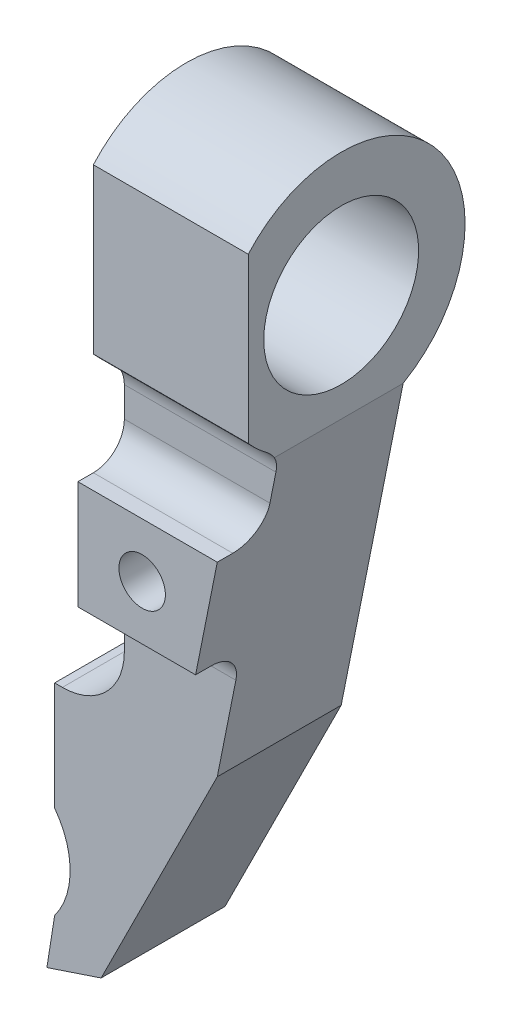
from build123d import *

# Parameters (mm, degrees)
BOSS_EXTRU_1_DEPTH           = 8
CONG_1_R                     = 4
ESQUISSE2_R                  = 5
ENL_V_MAT_EXTRU_1_DEPTH      = 9
BOSS_EXTRU_2_DEPTH           = 8
ESQUISSE4_R                  = 5
BOSS_EXTRU_3_DEPTH           = 10
ENL_V_MAT_EXTRU_2_DEPTH      = 1
ENL_V_MAT_EXTRU_2_DEPTH_BACK = 16
BOSS_EXTRU_4_DEPTH           = 3
CONG_2_R                     = 2
ESQUISSE7_R                  = 1.5
ENL_V_MAT_EXTRU_3_DEPTH      = 16


with BuildPart() as part:
    # Esquisse1 → Boss.-Extru.1 (new body)
    with BuildSketch(Plane.XY):
        Polygon((0, 0), (10, 0), (6, -20), (-1.5, -35), (-4.5, -36), (-4.5, -20), (0, -20), align=None)
    extrude(amount=BOSS_EXTRU_1_DEPTH)

    # Congé1
    cong_1_edges = [part.edges().sort_by_distance(p)[0] for p in [
        (0, -20, 4),
    ]]
    fillet(cong_1_edges, radius=CONG_1_R)

    # Esquisse2 → Enlèv. mat.-Extru.1 (cut, through all)
    with BuildSketch(Plane.XY.offset(8)):
        with Locations((-8.5, -30)):
            Circle(ESQUISSE2_R)
    extrude(amount=-ENL_V_MAT_EXTRU_1_DEPTH, mode=Mode.SUBTRACT)

    # Esquisse3 → Boss.-Extru.2 (add)
    with BuildSketch(Plane.XY.offset(8)):
        Polygon((-4.5, -33), (-5, -36.166666667), (-4.5, -36), align=None)
    extrude(amount=-BOSS_EXTRU_2_DEPTH)

    # Esquisse4 → Boss.-Extru.3 (add)
    with BuildSketch(Plane.ZY):
        with BuildLine():
            Line((8, 0), (0, 0))
            ThreePointArc((0, 0), (4, 14.92820323), (8, 0))
        make_face()
        with Locations((4, 6.92820323)):
            Circle(ESQUISSE4_R, mode=Mode.SUBTRACT)
    extrude(amount=-BOSS_EXTRU_3_DEPTH)

    # Esquisse5 → Enlèv. mat.-Extru.2 (cut, two sides)
    with BuildSketch(Plane(origin=(10, 0, 0), x_dir=(0, 0, -1), z_dir=(1, 0, 0))) as enl_v_mat_extru_2_sk:
        Polygon((-10, 122.961773442), (-10, 12.219705852), (-10, 1.636700608), (-10, -109.105366981), (-231.484135179, -109.105366981), (-231.484135179, 122.961773442), align=None)
    extrude(amount=ENL_V_MAT_EXTRU_2_DEPTH, mode=Mode.SUBTRACT)
    extrude(enl_v_mat_extru_2_sk.sketch, amount=-ENL_V_MAT_EXTRU_2_DEPTH_BACK, mode=Mode.SUBTRACT)

    # Esquisse6 → Boss.-Extru.4 (add)
    with BuildSketch(Plane.XY.offset(8)):
        Polygon((0, -5), (0, -12), (7.6, -12), (9, -5), align=None)
    extrude(amount=BOSS_EXTRU_4_DEPTH)

    # Congé2
    cong_2_edges = [part.edges().sort_by_distance(p)[0] for p in [
        (5, 0, 8),
        (4.5, -5, 8),
        (3.8, -12, 8),
    ]]
    fillet(cong_2_edges, radius=CONG_2_R)

    # Esquisse7 → Enlèv. mat.-Extru.3 (cut, through all)
    with BuildSketch(Plane.XY.offset(11)):
        with Locations((4.15, -8.5)):
            Circle(ESQUISSE7_R)
    extrude(amount=-ENL_V_MAT_EXTRU_3_DEPTH, mode=Mode.SUBTRACT)


solid = part.part
